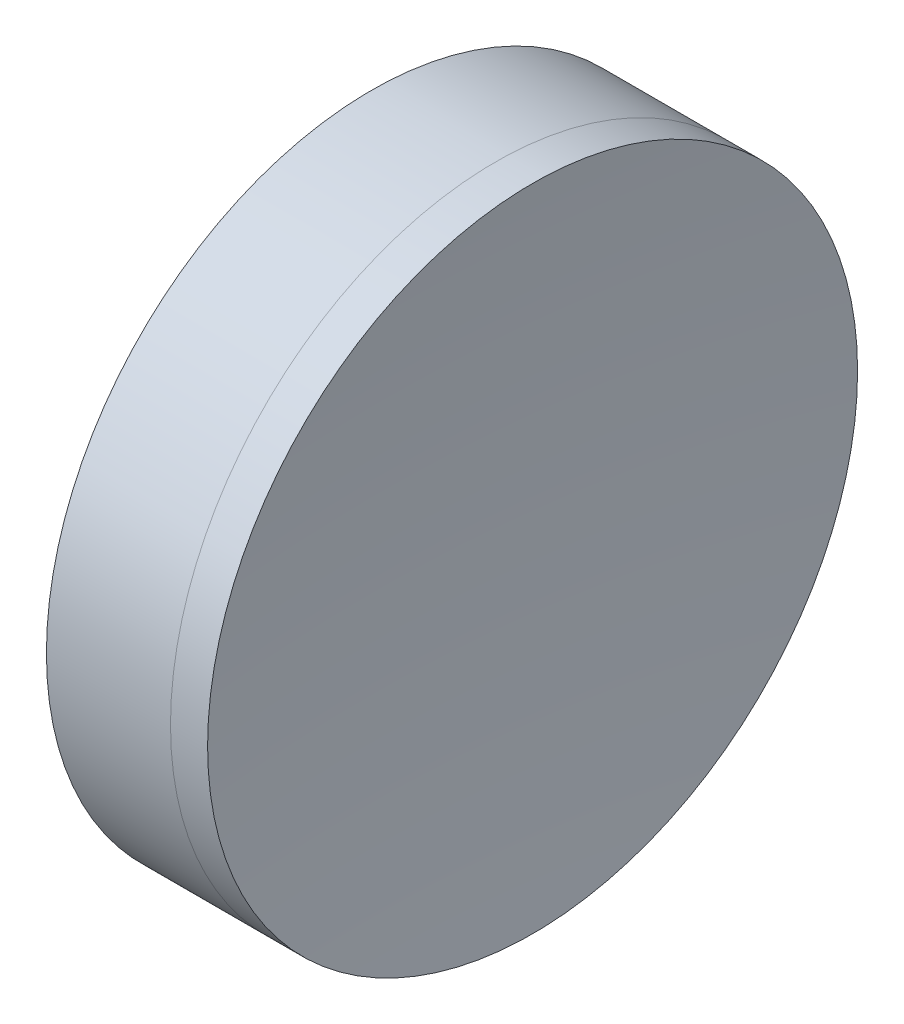
from build123d import *


with BuildPart() as part:
    # 草图1 one side → 旋转1 (revolve)
    with BuildSketch(Plane(origin=(0, 0, 0), x_dir=(1, 0, 0), z_dir=(0, 1, 0)), mode=Mode.PRIVATE) as revolve_1_sk:
        with BuildLine():
            Line((251.228623365, 20), (243.593238138, 20))
            ThreePointArc((243.593238138, 20), (245.248742769, 10.060842587), (245.802811453, 0))
            Line((245.802811453, 0), (248.302811453, 0))
            ThreePointArc((248.302811453, 0), (249.038136552, 10.106438237), (251.228623365, 20))
        make_face()
    revolve(revolve_1_sk.sketch.rotate(Axis((-0.816062176, 0, 0), (1, 0, 0)), 180), axis=Axis((-0.816062176, 0, 0), (1, 0, 0)))  # turned: the seam where the file's is


with BuildPart() as body_2:
    # 草图2 one side → 旋转3 (revolve)
    with BuildSketch(Plane(origin=(0, 0, 0), x_dir=(1, 0, 0), z_dir=(0, 1, 0))):
        with BuildLine():
            Line((253.511950082, 20), (251.228623365, 20))
            ThreePointArc((251.228623365, 20), (249.038136552, 10.106438237), (248.302811453, 0))
            Line((248.302811453, 0), (252.552811453, 0))
            ThreePointArc((252.552811453, 0), (252.79273382, 10.011492732), (253.511950082, 20))
        make_face()
    revolve(axis=Axis((243.593238138, 0, 0), (1, 0, 0)))


solid = Compound([part.part, body_2.part])
